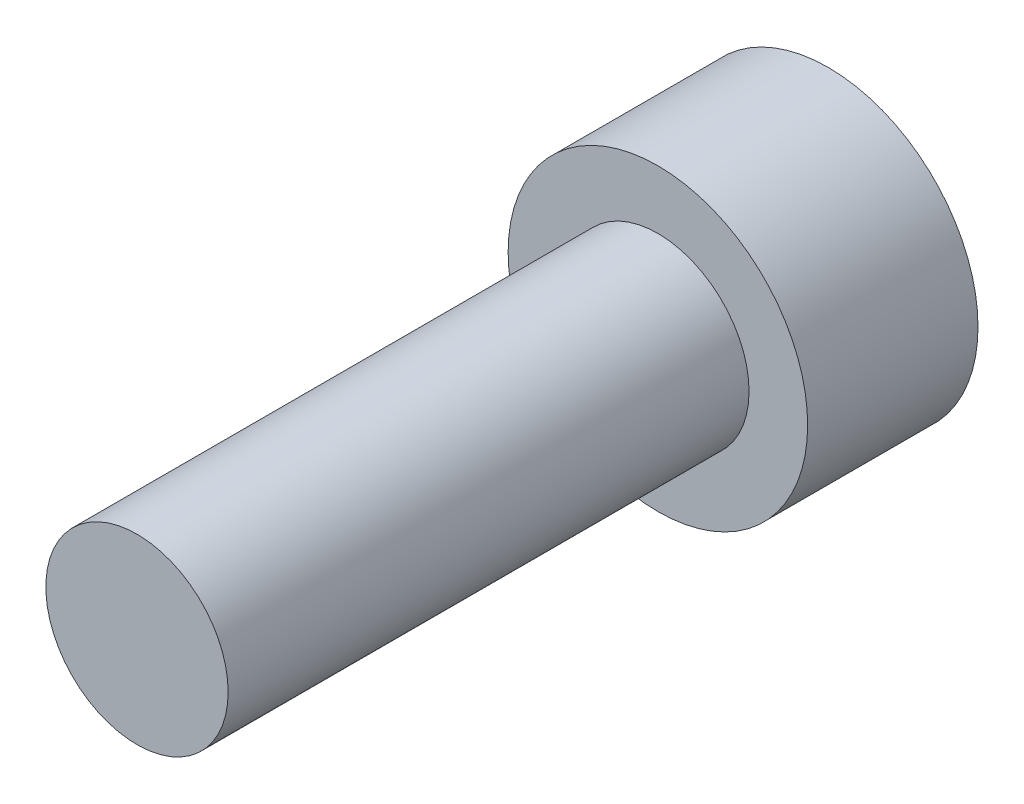
from build123d import *

# Parameters (mm, degrees)
SKETCH_1_R      = 2.875
EXTRUDE_1_DEPTH = 3.27
SKETCH_2_R      = 1.75
EXTRUDE_2_DEPTH = 10


with BuildPart() as part:
    # 草图1 → 凸台-拉伸1 (new body)
    with BuildSketch(Plane.XY):
        Circle(SKETCH_1_R)
    extrude(amount=EXTRUDE_1_DEPTH)

    # 草图2 → 凸台-拉伸2 (add)
    with BuildSketch(Plane.XY.offset(3.27)):
        Circle(SKETCH_2_R)
    extrude(amount=EXTRUDE_2_DEPTH)


solid = part.part
